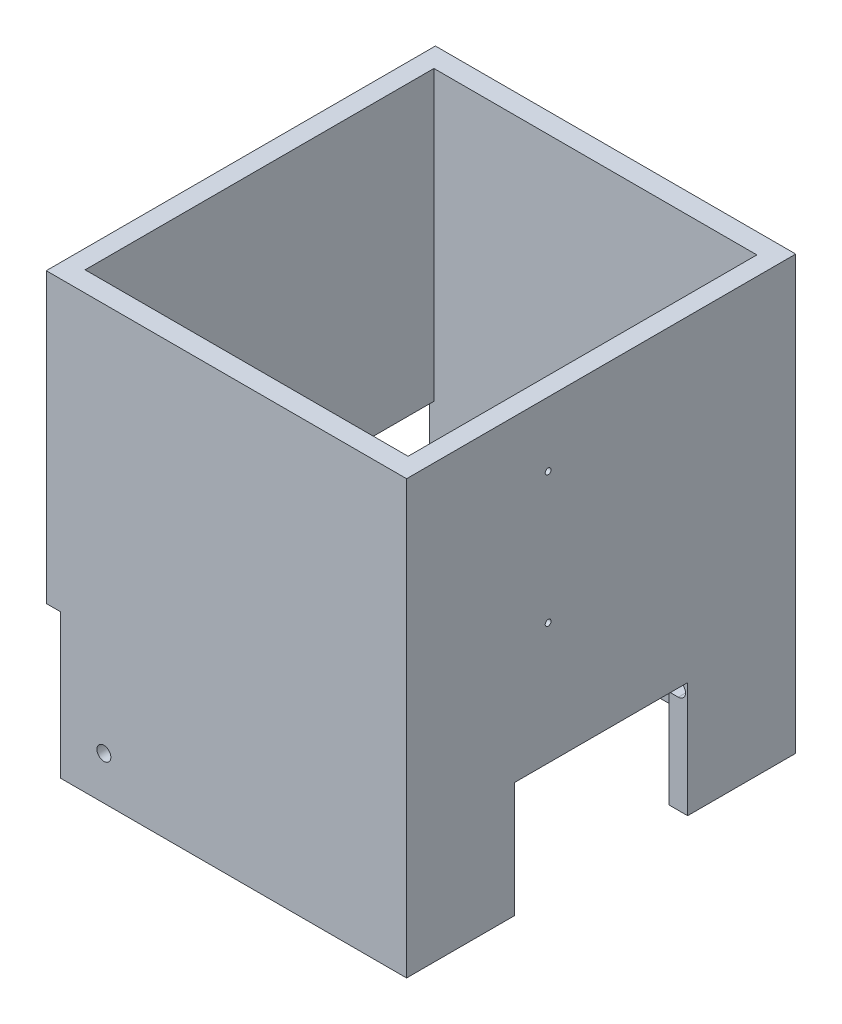
from build123d import *

# Parameters (mm, degrees)
SKETCH1_W                       = 125
SKETCH1_H                       = 135
SKETCH1_W_2                     = 112.037037038
SKETCH1_H_2                     = 121
BOSS_EXTRUDE1_DEPTH             = 150
SKETCH3_W                       = 5
SKETCH3_H                       = 50
CUT_EXTRUDE1_DEPTH              = 68.5
CUT_EXTRUDE1_DEPTH_BACK         = 68.5
CUT_EXTRUDE2_REACH              = 127
SKETCH4_W                       = 60
SKETCH4_H                       = 40
CUT_EXTRUDE3_DEPTH              = 37.5
F_2_CLEARANCE_HOLE1_D           = 2.032
F_2_CLEARANCE_HOLE1_DEPTH       = 6.481481481
F_3_CLEARANCE_HOLE1_D           = 2.54
F_3_CLEARANCE_HOLE1_DEPTH       = 3.175
F_3_CLEARANCE_HOLE1_CSINK_D     = 3.9116
F_3_CLEARANCE_HOLE1_CSINK_ANGLE = 90
F_3_CLEARANCE_HOLE1_TIP         = 0.763092986
CUT_EXTRUDE4_REACH              = 122
SKETCH19_W                      = 121
SKETCH19_H                      = 50


with BuildPart() as part:
    # Sketch1 → Boss-Extrude1 (new body)
    with BuildSketch(Plane(origin=(0, 0, 0), x_dir=(1, 0, 0), z_dir=(0, 1, 0))):
        Rectangle(SKETCH1_W, SKETCH1_H)
        Rectangle(SKETCH1_W_2, SKETCH1_H_2, mode=Mode.SUBTRACT)
    extrude(amount=BOSS_EXTRUDE1_DEPTH)

    # Sketch3 → Cut-Extrude1 (cut, two sides)
    with BuildSketch(Plane.XY) as cut_extrude1_sk:
        with Locations((-60, 25)):
            Rectangle(SKETCH3_W, SKETCH3_H)
    extrude(amount=CUT_EXTRUDE1_DEPTH, mode=Mode.SUBTRACT)
    extrude(cut_extrude1_sk.sketch, amount=-CUT_EXTRUDE1_DEPTH_BACK, mode=Mode.SUBTRACT)

    # Sketch4 → Cut-Extrude2 (cut, up to next)
    with BuildSketch(Plane(origin=(62.5, 0, 0), x_dir=(0, 0, -1), z_dir=(1, 0, 0)), mode=Mode.PRIVATE) as cut_extrude2_sk1:
        with Locations((0, 20)):
            Rectangle(SKETCH4_W, SKETCH4_H)
    cut_extrude2_tool1 = extrude(cut_extrude2_sk1.sketch, amount=-CUT_EXTRUDE2_REACH, mode=Mode.PRIVATE) & part.part
    add(cut_extrude2_tool1.solids().sort_by_distance((62.5, 20, 0))[0], mode=Mode.SUBTRACT)

    # Sketch11 → #10 Clearance Hole1 (revolve, cut)
    with BuildSketch(Plane(origin=(-42.5, 15, 67.5), x_dir=(0, -1, 0), z_dir=(1, 0, 0))):
        Polygon((0, 0), (0, 26.849876674), (2.413, 25.4), (2.413, 0), align=None)
    f_10_clearance_hole1 = revolve(axis=Axis((-42.5, 15, 73.85), (0, 0, -1)), mode=Mode.SUBTRACT)

    # Mirror1: #10 Clearance Hole1 across plane
    add(f_10_clearance_hole1.mirror(Plane.XY), mode=Mode.SUBTRACT)

    # Sketch12 → Cut-Extrude3 (cut, symmetric)
    with BuildSketch(Plane.XY):
        with BuildLine():
            Line((56.018518519, 39), (56.018518519, 34))
            Line((56.018518519, 34), (59.259259259, 34))
            ThreePointArc((59.259259259, 34), (61.759259259, 36.5), (59.259259259, 39))
            Line((59.259259259, 39), (56.018518519, 39))
        make_face()
    extrude(amount=CUT_EXTRUDE3_DEPTH, both=True, mode=Mode.SUBTRACT)

    # #2 Clearance Hole1
    with Locations(Plane(origin=(62.5, 0, 0), x_dir=(0, 0, -1), z_dir=(1, 0, 0))):
        with Locations((-18.3915, 127.656921), (-18.3915, 82.156921)):
            Hole(F_2_CLEARANCE_HOLE1_D / 2, depth=F_2_CLEARANCE_HOLE1_DEPTH)

    # #3 Clearance Hole1
    with Locations(Plane(origin=(-56.018518519, 0, 0), x_dir=(0, 0, -1), z_dir=(1, 0, 0))):
        with Locations((10.2126, 67.112098568), (18.7126, 67.112098568)):
            CounterSinkHole(F_3_CLEARANCE_HOLE1_D / 2, F_3_CLEARANCE_HOLE1_CSINK_D / 2, depth=F_3_CLEARANCE_HOLE1_DEPTH, counter_sink_angle=F_3_CLEARANCE_HOLE1_CSINK_ANGLE)
            with Locations((0, 0, -(F_3_CLEARANCE_HOLE1_DEPTH + F_3_CLEARANCE_HOLE1_TIP / 2))):  # 118° drill point
                Cone(0, F_3_CLEARANCE_HOLE1_D / 2, F_3_CLEARANCE_HOLE1_TIP, mode=Mode.SUBTRACT)

    # Sketch19 → Cut-Extrude4 (cut, up to next)
    with BuildSketch(Plane.ZY.offset(57.5), mode=Mode.PRIVATE) as cut_extrude4_sk1:
        with Locations((0, 25)):
            Rectangle(SKETCH19_W, SKETCH19_H)
    cut_extrude4_tool1 = extrude(cut_extrude4_sk1.sketch, amount=-CUT_EXTRUDE4_REACH, mode=Mode.PRIVATE) & part.part
    add(cut_extrude4_tool1.solids().sort_by_distance((-57.5, 25, 0))[0], mode=Mode.SUBTRACT)


solid = part.part
